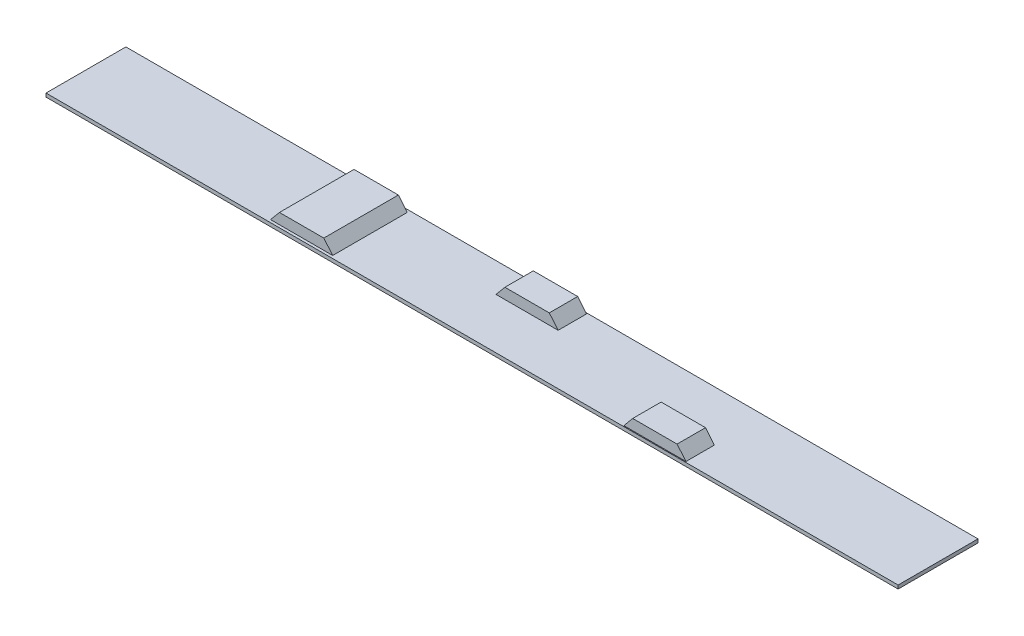
from build123d import *

# Parameters (mm, degrees)
SKETCH1_W                = 2400
SKETCH1_H                = 225
BOSS_EXTRUDE1_DEPTH      = 10
BOSS_EXTRUDE2_START      = 30
BOSS_EXTRUDE2_DEPTH      = 80
BOSS_EXTRUDE3_START      = -30
BOSS_EXTRUDE3_DEPTH      = 80
BOSS_EXTRUDE4_DEPTH      = 105
BOSS_EXTRUDE4_DEPTH_BACK = 105


with BuildPart() as part:
    # Sketch1 → Boss-Extrude1 (new body)
    with BuildSketch(Plane(origin=(0, 0, 0), x_dir=(1, 0, 0), z_dir=(0, 1, 0))):
        Rectangle(SKETCH1_W, SKETCH1_H)
    extrude(amount=BOSS_EXTRUDE1_DEPTH)

    # Sketch2 → Boss-Extrude2 (add)
    with BuildSketch(Plane.XY.offset(BOSS_EXTRUDE2_START)):
        Polygon((425, 10), (450, 40), (575, 40), (600, 10), align=None)
    extrude(amount=BOSS_EXTRUDE2_DEPTH)

    # Sketch4 → Boss-Extrude3 (add)
    with BuildSketch(Plane.XY.offset(BOSS_EXTRUDE3_START)):
        Polygon((-50, 40), (-75, 10), (100, 10), (75, 40), align=None)
    extrude(amount=-BOSS_EXTRUDE3_DEPTH)

    # Sketch5 → Boss-Extrude4 (add, two sides)
    with BuildSketch(Plane.XY) as boss_extrude4_sk:
        Polygon((-550, 40), (-575, 10), (-400, 10), (-425, 40), align=None)
    extrude(amount=BOSS_EXTRUDE4_DEPTH)
    extrude(boss_extrude4_sk.sketch, amount=-BOSS_EXTRUDE4_DEPTH_BACK)


solid = part.part
